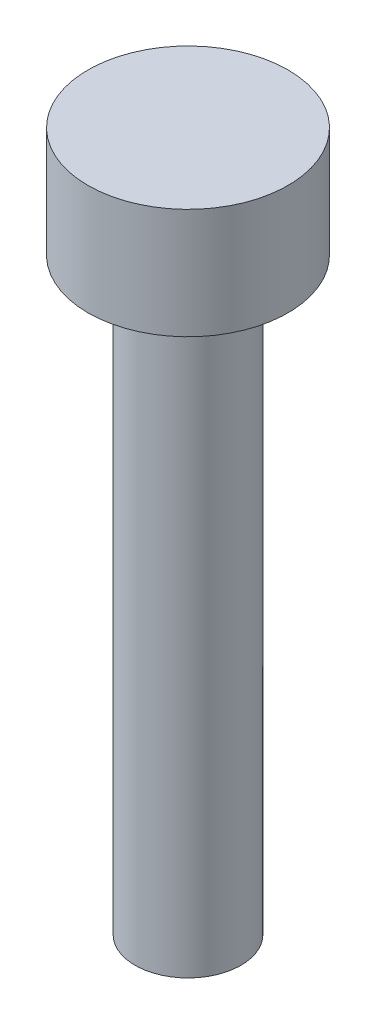
from build123d import *

# Parameters (mm, degrees)
SKETCH1_R           = 2.72
BOSS_EXTRUDE1_DEPTH = 3
SKETCH2_R           = 1.44
BOSS_EXTRUDE2_DEPTH = 16


with BuildPart() as part:
    # Sketch1 → Boss-Extrude1 (new body)
    with BuildSketch(Plane(origin=(0, 0, 0), x_dir=(1, 0, 0), z_dir=(0, 1, 0))):
        Circle(SKETCH1_R)
    extrude(amount=BOSS_EXTRUDE1_DEPTH)

    # Sketch2 → Boss-Extrude2 (add)
    with BuildSketch(Plane.XZ):
        Circle(SKETCH2_R)
    extrude(amount=BOSS_EXTRUDE2_DEPTH)


solid = part.part
